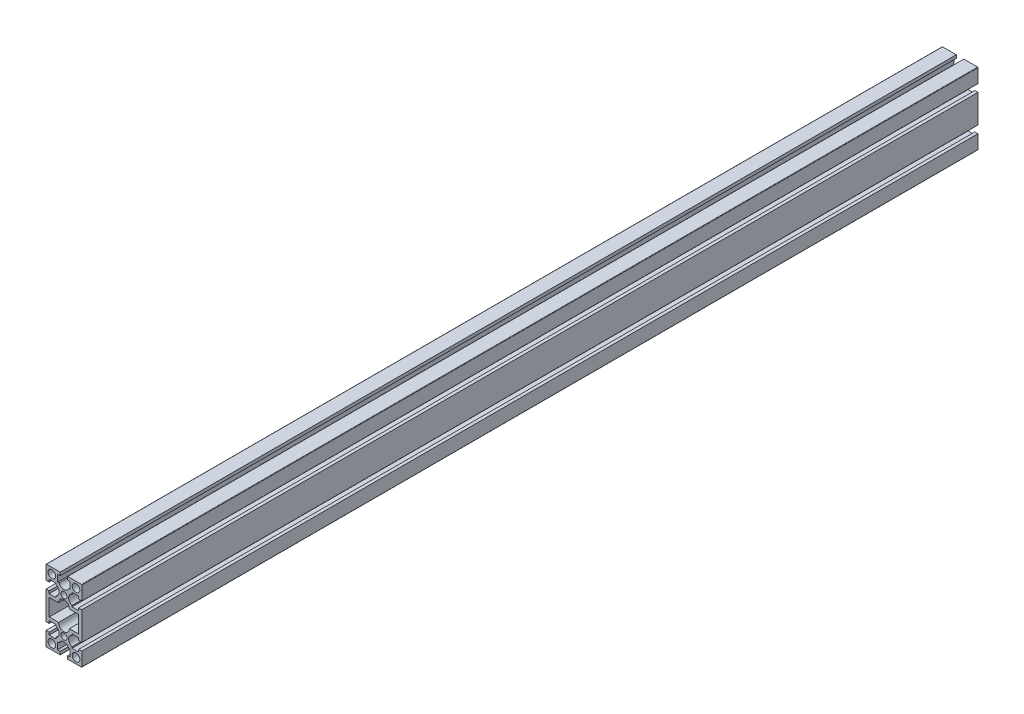
from build123d import *

# Parameters (mm, degrees)
SKETCH_1_R      = 4.25
SKETCH_1_R_2    = 3.4
EXTRUDE_1_DEPTH = 1000


with BuildPart() as part:
    # Эскиз1 → Бобышка-Вытянуть1 (new body)
    with BuildSketch(Plane.XY):
        with BuildLine():
            Line((-20, 19.5), (-20, 7))
            Line((-20, 7), (-20, 4.2))
            Line((-20, 4.2), (-16.5, 4.2))
            Line((-16.5, 4.2), (-16.5, 7))
            Line((-16.5, 7), (-9, 7))
            Line((-9, 7), (-9, 5.541660401))
            ThreePointArc((-9, 5.541660401), (-5.3, 0), (-9, -5.541660401))
            Line((-9, -5.541660401), (-9, -7))
            Line((-9, -7), (-16.5, -7))
            Line((-16.5, -7), (-16.5, -4.2))
            Line((-16.5, -4.2), (-20, -4.2))
            Line((-20, -4.2), (-20, -7))
            Line((-20, -7), (-20, -33))
            Line((-20, -33), (-20, -35.8))
            Line((-20, -35.8), (-16.5, -35.8))
            Line((-16.5, -35.8), (-16.5, -33))
            Line((-16.5, -33), (-9, -33))
            Line((-9, -33), (-9, -34.458339599))
            ThreePointArc((-9, -34.458339599), (-5.3, -40), (-9, -45.541660401))
            Line((-9, -45.541660401), (-9, -47))
            Line((-9, -47), (-16.5, -47))
            Line((-16.5, -47), (-16.5, -44.2))
            Line((-16.5, -44.2), (-20, -44.2))
            Line((-20, -44.2), (-20, -47))
            Line((-20, -47), (-20, -59.5))
            ThreePointArc((-20, -59.5), (-19.853553391, -59.853553391), (-19.5, -60))
            Line((-19.5, -60), (-7, -60))
            Line((-7, -60), (-4.2, -60))
            Line((-4.2, -60), (-4.2, -56.5))
            Line((-4.2, -56.5), (-7, -56.5))
            Line((-7, -56.5), (-7, -49))
            Line((-7, -49), (-5.541660401, -49))
            ThreePointArc((-5.541660401, -49), (0, -45.3), (5.541660401, -49))
            Line((5.541660401, -49), (7, -49))
            Line((7, -49), (7, -56.5))
            Line((7, -56.5), (4.2, -56.5))
            Line((4.2, -56.5), (4.2, -60))
            Line((4.2, -60), (7, -60))
            Line((7, -60), (19.5, -60))
            ThreePointArc((19.5, -60), (19.853553391, -59.853553391), (20, -59.5))
            Line((20, -59.5), (20, -47))
            Line((20, -47), (20, -44.2))
            Line((20, -44.2), (16.5, -44.2))
            Line((16.5, -44.2), (16.5, -47))
            Line((16.5, -47), (9, -47))
            Line((9, -47), (9, -45.541660401))
            ThreePointArc((9, -45.541660401), (5.3, -40), (9, -34.458339599))
            Line((9, -34.458339599), (9, -33))
            Line((9, -33), (16.5, -33))
            Line((16.5, -33), (16.5, -35.8))
            Line((16.5, -35.8), (20, -35.8))
            Line((20, -35.8), (20, -33))
            Line((20, -33), (20, -7))
            Line((20, -7), (20, -4.2))
            Line((20, -4.2), (16.5, -4.2))
            Line((16.5, -4.2), (16.5, -7))
            Line((16.5, -7), (9, -7))
            Line((9, -7), (9, -5.541660401))
            ThreePointArc((9, -5.541660401), (5.3, 0), (9, 5.541660401))
            Line((9, 5.541660401), (9, 7))
            Line((9, 7), (16.5, 7))
            Line((16.5, 7), (16.5, 4.2))
            Line((16.5, 4.2), (20, 4.2))
            Line((20, 4.2), (20, 7))
            Line((20, 7), (20, 19.5))
            ThreePointArc((20, 19.5), (19.853553391, 19.853553391), (19.5, 20))
            Line((19.5, 20), (7, 20))
            Line((7, 20), (4.2, 20))
            Line((4.2, 20), (4.2, 16.5))
            Line((4.2, 16.5), (7, 16.5))
            Line((7, 16.5), (7, 9))
            Line((7, 9), (5.541660401, 9))
            ThreePointArc((5.541660401, 9), (0, 5.3), (-5.541660401, 9))
            Line((-5.541660401, 9), (-7, 9))
            Line((-7, 9), (-7, 16.5))
            Line((-7, 16.5), (-4.2, 16.5))
            Line((-4.2, 16.5), (-4.2, 20))
            Line((-4.2, 20), (-7, 20))
            Line((-7, 20), (-19.5, 20))
            ThreePointArc((-19.5, 20), (-19.853553391, 19.853553391), (-20, 19.5))
        make_face()
        with Locations((-13.5, -53.5)):
            Circle(SKETCH_1_R, mode=Mode.SUBTRACT)
        with Locations((13.5, -53.5)):
            Circle(SKETCH_1_R, mode=Mode.SUBTRACT)
        with Locations((0, -40)):
            Circle(SKETCH_1_R_2, mode=Mode.SUBTRACT)
        with Locations((-13.5, 13.5)):
            Circle(SKETCH_1_R, mode=Mode.SUBTRACT)
        with BuildLine():
            Line((16.4, -10.5), (16.4, -29.5))
            Line((16.4, -29.5), (6, -29.5))
            ThreePointArc((6, -29.5), (0, -35.5), (-6, -29.5))
            Line((-6, -29.5), (-16.4, -29.5))
            Line((-16.4, -29.5), (-16.4, -10.5))
            Line((-16.4, -10.5), (-6, -10.5))
            ThreePointArc((-6, -10.5), (0, -4.5), (6, -10.5))
            Line((6, -10.5), (16.4, -10.5))
        make_face(mode=Mode.SUBTRACT)
        Circle(SKETCH_1_R_2, mode=Mode.SUBTRACT)
        with Locations((13.5, 13.5)):
            Circle(SKETCH_1_R, mode=Mode.SUBTRACT)
    extrude(amount=EXTRUDE_1_DEPTH)


solid = part.part
